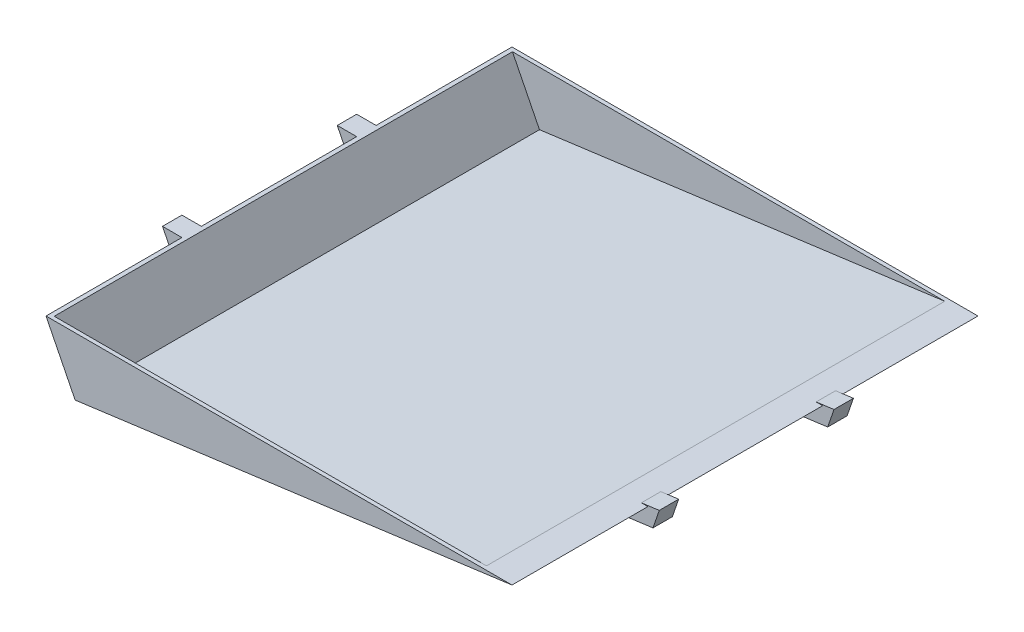
from build123d import *

# Parameters (mm, degrees)
BOSS_EXTRUDE1_DEPTH = 609.6
SHELL1_T            = -5.08
SKETCH1_W           = 25.4
SKETCH1_H           = 25.4
BOSS_EXTRUDE5_DEPTH = 203.2


with BuildPart() as part:
    # 3DSketch1 → Boss-Extrude1 (new body)
    with BuildSketch(Plane(origin=(574.750801769, 1402.417106037, 1756.25455637), x_dir=(1, 0, 0), z_dir=(0, 0, -1))):
        Polygon((0, 0), (38.1, 76.2), (609.6, 0), align=None)
    extrude(amount=BOSS_EXTRUDE1_DEPTH)

    # Shell1
    shell1_openings = [part.faces().sort_by_distance(p)[0] for p in [
        (879.550801769, 1402.417106037, 1451.45455637),
    ]]
    offset(amount=SHELL1_T, openings=shell1_openings, kind=Kind.INTERSECTION)

    # Sweep1: sweep along a path in Sketch3
    with BuildLine(Plane.XY.offset(1565.75455637)) as sweep1_path:
        Line((562.050801769, 1402.417106037), (605.783819273, 1314.951071029))
        Line((605.783819273, 1314.951071029), (1195.063819273, 1393.521737696))
    # Sketch1 → Sweep1 (sweep)
    with BuildSketch(Plane(origin=(0, 1402.417106037, 0), x_dir=(1, 0, 0), z_dir=(0, 1, 0))):
        with Locations((562.050801769, -1565.75455637)):
            Rectangle(SKETCH1_W, SKETCH1_H)
    sweep1 = sweep(path=sweep1_path.line, transition=Transition.RIGHT)

    # Mirror1: Sweep1 across plane
    add(sweep1.mirror(Plane.XY.offset(1451.45455637)))


with BuildPart() as body_2:
    # Sketch4 → Boss-Extrude5 (new body)
    with BuildSketch(Plane(origin=(0, 0, 1553.05455637), x_dir=(-1, 0, 0), z_dir=(0, 0, -1))):
        Polygon((-599.249327743, 1302.620054088), (-624.649327743, 1306.006720755), (-612.850801769, 1326.217106037), (-587.890102418, 1325.33850474), align=None)
    extrude(amount=BOSS_EXTRUDE5_DEPTH)


solid = Compound([part.part, body_2.part])
